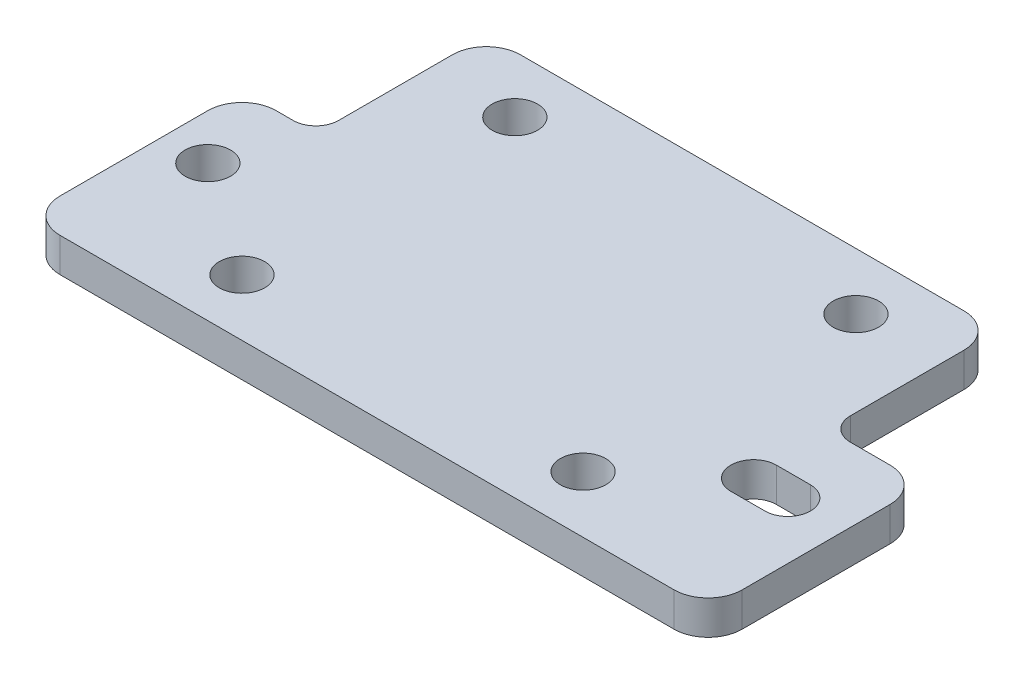
from build123d import *

# Parameters (mm, degrees)
SKETCH1_R           = 2
SKETCH1_W           = 6.5
SKETCH1_H           = 19
SKETCH1_W_2         = 45
SKETCH1_H_2         = 15
BOSS_EXTRUDE1_DEPTH = 3
FILLET1_R           = 3
FILLET2_R           = 2


with BuildPart() as part:
    # Sketch1 → Boss-Extrude1 (new body)
    with BuildSketch(Plane(origin=(0, 0, 0), x_dir=(1, 0, 0), z_dir=(0, 1, 0))):
        with BuildLine():
            Line((-22.5, 2), (-22.5, -17))
            Line((-22.5, -17), (22.5, -17))
            Line((22.5, -17), (22.5, -6.936491673))
            ThreePointArc((22.5, -6.936491673), (21, -5), (22.5, -3.063508327))
            Line((22.5, -3.063508327), (22.5, 2))
            Line((22.5, 2), (-22.5, 2))
        make_face()
        with Locations((-15, -12)):
            Circle(SKETCH1_R, mode=Mode.SUBTRACT)
        with Locations((15, -12)):
            Circle(SKETCH1_R, mode=Mode.SUBTRACT)
        with Locations((-25.75, -7.5)):
            Rectangle(SKETCH1_W, SKETCH1_H)
        with Locations((-25, -5)):
            Circle(SKETCH1_R, mode=Mode.SUBTRACT)
        with Locations((0, 9.5)):
            Rectangle(SKETCH1_W_2, SKETCH1_H_2)
        with Locations((-15, 12)):
            Circle(SKETCH1_R, mode=Mode.SUBTRACT)
        with Locations((15, 12)):
            Circle(SKETCH1_R, mode=Mode.SUBTRACT)
        with BuildLine():
            Line((22.5, -6.936491673), (22.5, -17))
            Line((22.5, -17), (31, -17))
            Line((31, -17), (31, 2))
            Line((31, 2), (22.5, 2))
            Line((22.5, 2), (22.5, -3.063508327))
            ThreePointArc((22.5, -3.063508327), (22.747991415, -3.015940607), (23, -3))
            Line((23, -3), (26, -3))
            ThreePointArc((26, -3), (28, -5), (26, -7))
            Line((26, -7), (23, -7))
            ThreePointArc((23, -7), (22.747991415, -6.984059393), (22.5, -6.936491673))
        make_face()
    extrude(amount=BOSS_EXTRUDE1_DEPTH)

    # Fillet1
    fillet1_edges = [part.edges().sort_by_distance(p)[0] for p in [
        (31, 1.5, -2),
        (31, 1.5, 17),
        (-29, 1.5, 17),
        (-29, 1.5, -2),
        (-22.5, 1.5, -17),
        (22.5, 1.5, -17),
    ]]
    fillet(fillet1_edges, radius=FILLET1_R)

    # Fillet2
    fillet2_edges = [part.edges().sort_by_distance(p)[0] for p in [
        (-22.5, 1.5, -2),
        (22.5, 1.5, -2),
    ]]
    fillet(fillet2_edges, radius=FILLET2_R)


solid = part.part
